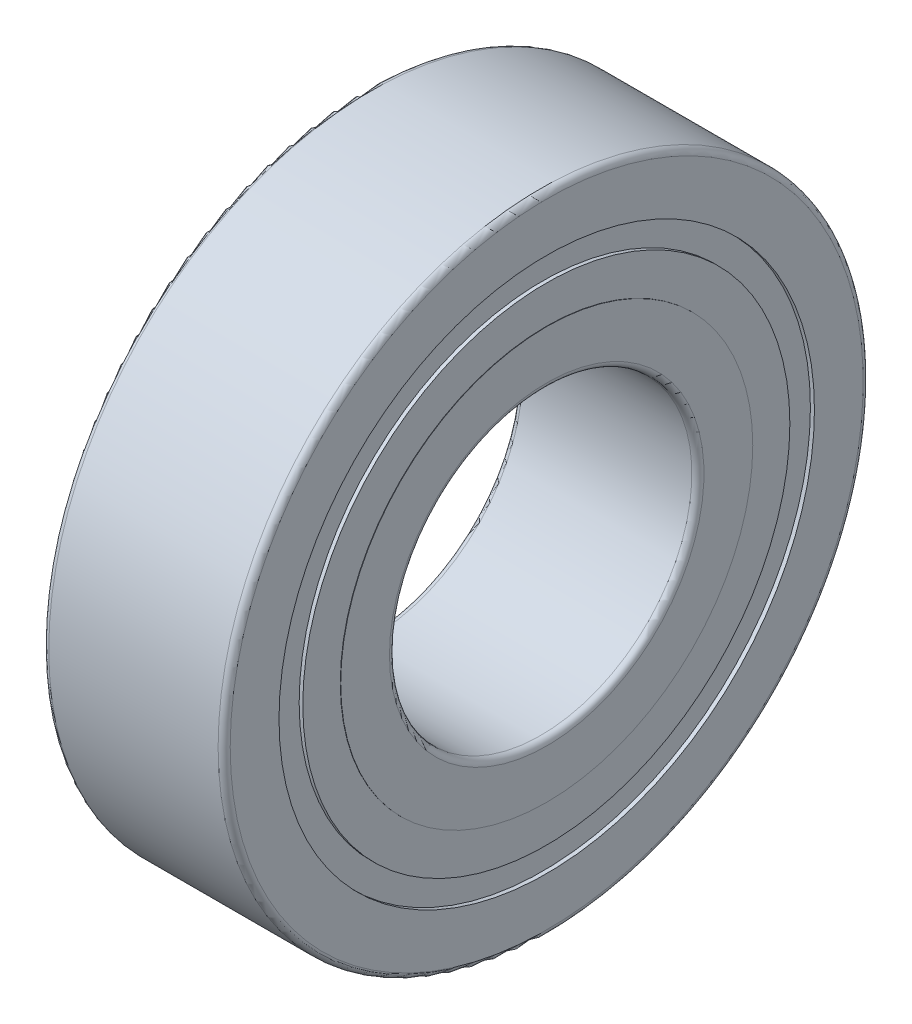
from build123d import *

# Parameters (mm, degrees)
SCALE1_SCALE = 3.2


with BuildPart() as part:
    # Sketch1 → Revolve1 (revolve)
    with BuildSketch(Plane.XY):
        with BuildLine():
            Line((-4.5, 15.7), (-4.5, 7.8))
            ThreePointArc((-4.5, 7.8), (-4.412132034, 7.587867966), (-4.2, 7.5))
            Line((-4.2, 7.5), (4.2, 7.5))
            ThreePointArc((4.2, 7.5), (4.412132034, 7.587867966), (4.5, 7.8))
            Line((4.5, 7.8), (4.5, 15.7))
            ThreePointArc((4.5, 15.7), (4.412132034, 15.912132034), (4.2, 16))
            Line((4.2, 16), (-4.2, 16))
            ThreePointArc((-4.2, 16), (-4.412132034, 15.912132034), (-4.5, 15.7))
        make_face()
    revolve(axis=Axis((50, 0, 0), (-1, 0, 0)))

    # Sketch2 → Cut-Revolve1 (revolve, cut)
    with BuildSketch(Plane.XY):
        Polygon((-6.3, 7.5), (-4.5, 7.5), (-4.5, 10.22), (-4.48, 10.22), (-4.48, 12.08), (-4.3, 12.08), (-4.3, 13.28), (-6.3, 13.28), align=None)
    revolve(axis=Axis((50, 0, 0), (-1, 0, 0)), mode=Mode.SUBTRACT)

    # Sketch3 → Cut-Revolve2 (revolve, cut)
    with BuildSketch(Plane.XY):
        Polygon((4.3, 13.28), (4.3, 12.08), (4.48, 12.08), (4.48, 10.22), (4.5, 10.22), (4.5, 7.5), (6.3, 7.5), (6.3, 13.28), align=None)
    revolve(axis=Axis((50, 0, 0), (-1, 0, 0)), mode=Mode.SUBTRACT)


with BuildPart() as part_1:
    # Scale1: scaled about (0, 0, 0)
    add(part.part.scale(SCALE1_SCALE))


solid = part_1.part
